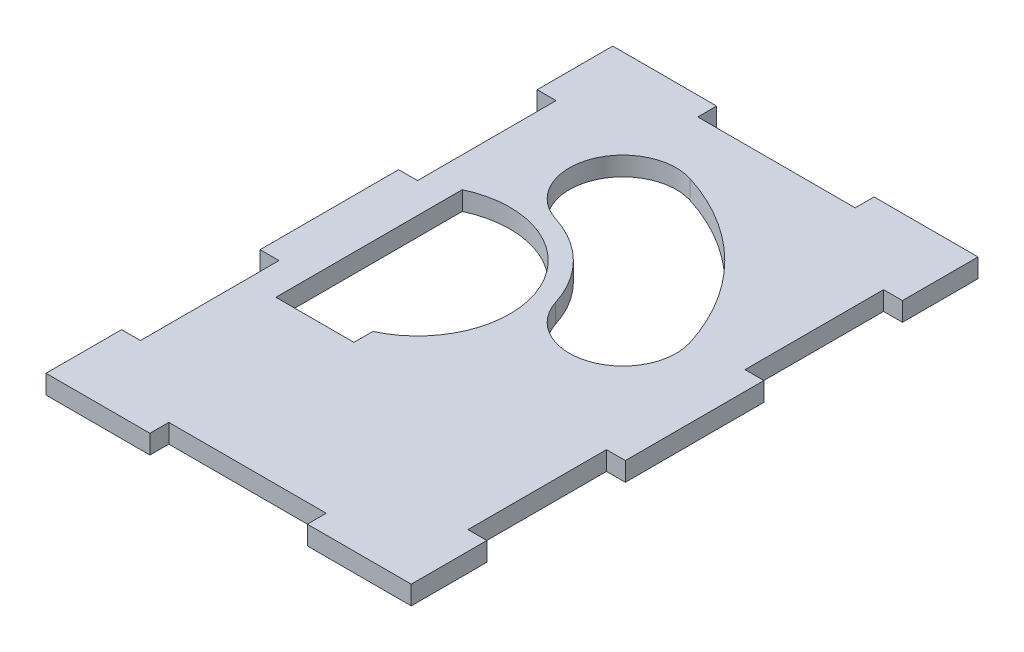
from build123d import *

# Parameters (mm, degrees)
BOSS_EXTRUDE2_DEPTH = 3


with BuildPart() as part:
    # Sketch4 → Boss-Extrude2 (new body)
    with BuildSketch(Plane(origin=(0, 0, 0), x_dir=(1, 0, 0), z_dir=(0, 1, 0))):
        Polygon((-26, -90), (-9.5, -90), (-9.5, -87), (15.5, -87), (15.5, -90), (32, -90), (32, -78), (29, -78), (29, -56), (32, -56), (32, -34), (29, -34), (29, -12), (32, -12), (32, 0), (15.5, 0), (15.5, -3), (-9.5, -3), (-9.5, 0), (-26, 0), (-26, -12), (-23, -12), (-23, -34), (-26, -34), (-26, -56), (-23, -56), (-23, -78), (-26, -78), align=None)
        with BuildLine():
            Line((-18.2, -61.3), (-5.8, -61.3))
            Line((-5.8, -61.3), (-5.8, -58.3))
            ThreePointArc((-5.8, -58.3), (1.3, -38.8), (-18.2, -31.7))
            Line((-18.2, -31.7), (-18.2, -61.3))
        make_face(mode=Mode.SUBTRACT)
        with BuildLine():
            ThreePointArc((4.693936025, -39.75), (0.374368671, -32.625631329), (-6.75, -28.306063975))
            ThreePointArc((-6.75, -28.306063975), (-12.308483212, -17.647580763), (-1.65, -12.089097551))
            ThreePointArc((-1.65, -12.089097551), (12.395183951, -20.604816049), (20.910902449, -34.65))
            ThreePointArc((20.910902449, -34.65), (15.352419237, -45.308483212), (4.693936025, -39.75))
        make_face(mode=Mode.SUBTRACT)
    extrude(amount=BOSS_EXTRUDE2_DEPTH)


solid = part.part
